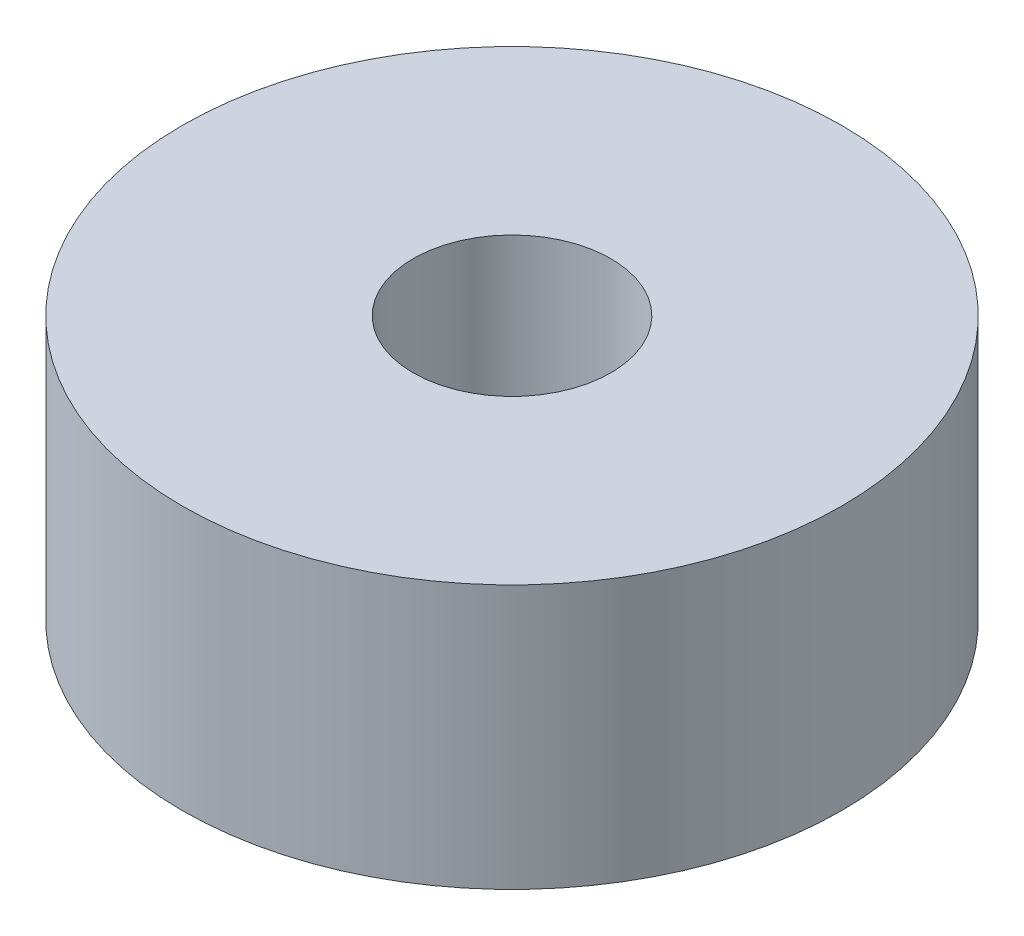
from build123d import *

# Parameters (mm, degrees)
SKETCH_1_R      = 5
SKETCH_1_R_2    = 1.5
EXTRUDE_1_DEPTH = 4


with BuildPart() as part:
    # 草图1 → 凸台-拉伸1 (new body)
    with BuildSketch(Plane(origin=(0, 0, 0), x_dir=(1, 0, 0), z_dir=(0, 1, 0))):
        Circle(SKETCH_1_R)
        Circle(SKETCH_1_R_2, mode=Mode.SUBTRACT)
    extrude(amount=EXTRUDE_1_DEPTH)


solid = part.part
